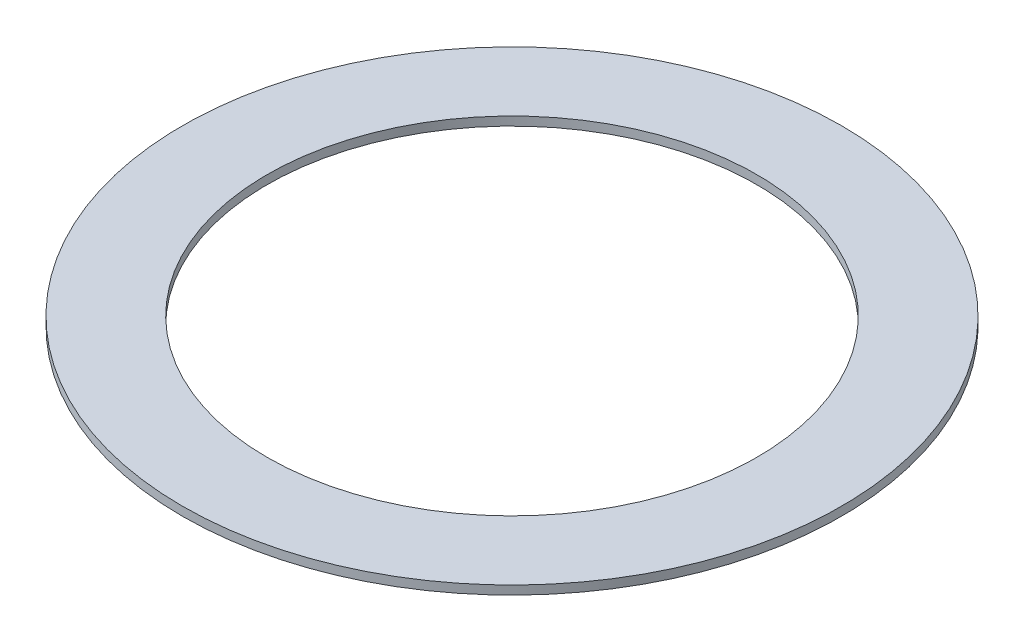
from build123d import *

# Parameters (mm, degrees)
SKETCH1_R           = 119.634
SKETCH1_R_2         = 88.9
BOSS_EXTRUDE1_DEPTH = 3.175


with BuildPart() as part:
    # Sketch1 → Boss-Extrude1 (new body)
    with BuildSketch(Plane(origin=(0, 0, 0), x_dir=(1, 0, 0), z_dir=(0, 1, 0))):
        Circle(SKETCH1_R)
        Circle(SKETCH1_R_2, mode=Mode.SUBTRACT)
    extrude(amount=BOSS_EXTRUDE1_DEPTH)


solid = part.part
